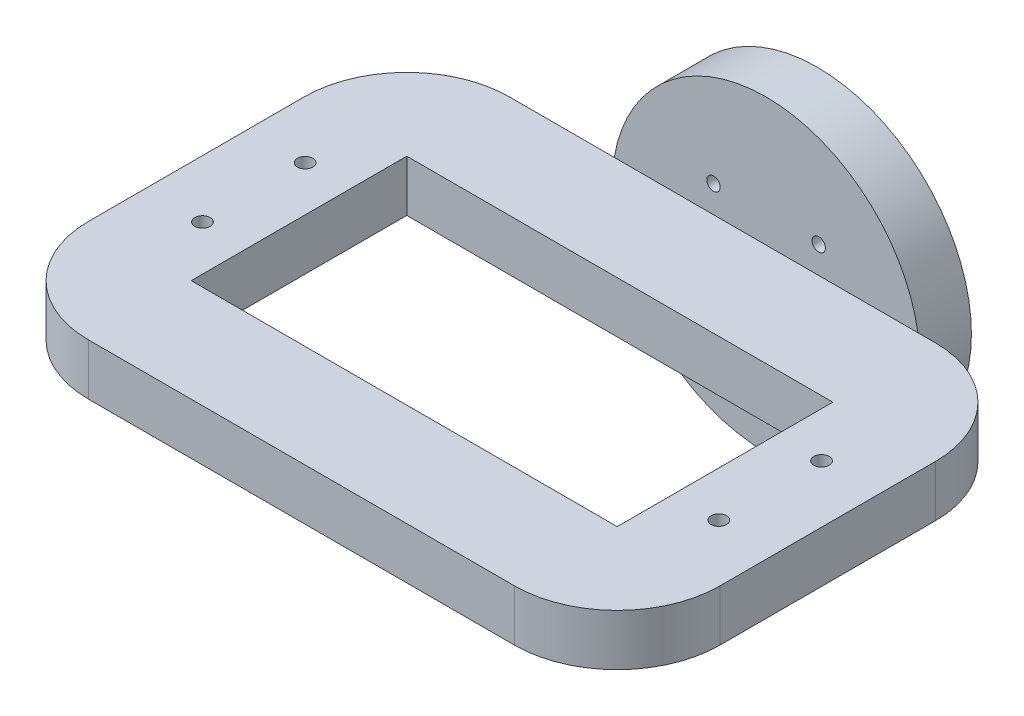
from build123d import *

# Parameters (mm, degrees)
SKETCH1_W           = 61.5
SKETCH1_H           = 30
BOSS_EXTRUDE2_DEPTH = 5
SKETCH2_W           = 61.5
SKETCH2_H           = 5
BOSS_EXTRUDE3_DEPTH = 41
SKETCH3_W           = 41.5
SKETCH3_H           = 21
CUT_EXTRUDE1_DEPTH  = 5
SKETCH4_OUTSIDE_W   = 79.99
SKETCH4_OUTSIDE_H   = 48.49
SKETCH4_OUTSIDE_R   = 15
CUT_EXTRUDE2_DEPTH  = 5
SKETCH5_R           = 3.25
CUT_EXTRUDE5_DEPTH  = 4
FILLET1_R           = 10
FILLET2_R           = 10
FILLET3_R           = 10
FILLET4_R           = 10
SKETCH7_R           = 0.75
CUT_EXTRUDE7_DEPTH  = 5
SKETCH8_R           = 0.65
CUT_EXTRUDE8_DEPTH  = 5


with BuildPart() as part:
    # Sketch1 → Boss-Extrude2 (new body)
    with BuildSketch(Plane.XY):
        with Locations((-30.75, 15)):
            Rectangle(SKETCH1_W, SKETCH1_H)
    extrude(amount=BOSS_EXTRUDE2_DEPTH)

    # Sketch2 → Boss-Extrude3 (add)
    with BuildSketch(Plane.XY.offset(5)):
        with Locations((-30.75, 15)):
            Rectangle(SKETCH2_W, SKETCH2_H)
    extrude(amount=BOSS_EXTRUDE3_DEPTH)

    # Sketch3 → Cut-Extrude1 (cut)
    with BuildSketch(Plane.XZ.offset(-12.5)):
        with Locations((-30.75, 25.5)):
            Rectangle(SKETCH3_W, SKETCH3_H)
    extrude(amount=-CUT_EXTRUDE1_DEPTH, mode=Mode.SUBTRACT)

    # Sketch4 outside → Cut-Extrude2 (cut)
    with BuildSketch(Plane(origin=(0, 0, 0), x_dir=(-1, 0, 0), z_dir=(0, 0, -1))):
        with Locations((30.75, 15)):
            Rectangle(SKETCH4_OUTSIDE_W, SKETCH4_OUTSIDE_H)
        with Locations((26.5, 15)):
            Circle(SKETCH4_OUTSIDE_R, mode=Mode.SUBTRACT)
    extrude(amount=-CUT_EXTRUDE2_DEPTH, mode=Mode.SUBTRACT)

    # Sketch5 → Cut-Extrude5 (cut)
    with BuildSketch(Plane(origin=(0, 0, 0), x_dir=(-1, 0, 0), z_dir=(0, 0, -1))):
        with Locations((26.5, 15)):
            Circle(SKETCH5_R)
    extrude(amount=-CUT_EXTRUDE5_DEPTH, mode=Mode.SUBTRACT)

    # Fillet1
    fillet1_edges = [part.edges().sort_by_distance(p)[0] for p in [
        (-61.5, 15, 5),
    ]]
    fillet(fillet1_edges, radius=FILLET1_R)

    # Fillet2
    fillet2_edges = [part.edges().sort_by_distance(p)[0] for p in [
        (-61.5, 15, 46),
    ]]
    fillet(fillet2_edges, radius=FILLET2_R)

    # Fillet3
    fillet3_edges = [part.edges().sort_by_distance(p)[0] for p in [
        (0, 15, 5),
    ]]
    fillet(fillet3_edges, radius=FILLET3_R)

    # Fillet4
    fillet4_edges = [part.edges().sort_by_distance(p)[0] for p in [
        (0, 15, 46),
    ]]
    fillet(fillet4_edges, radius=FILLET4_R)

    # Sketch7 → Cut-Extrude7 (cut)
    with BuildSketch(Plane.XZ.offset(-12.5)):
        with Locations((-55.9, 20.5)):
            Circle(SKETCH7_R)
        with Locations((-55.9, 30.5)):
            Circle(SKETCH7_R)
        with Locations((-5.6, 30.5)):
            Circle(SKETCH7_R)
        with Locations((-5.6, 20.5)):
            Circle(SKETCH7_R)
    extrude(amount=-CUT_EXTRUDE7_DEPTH, mode=Mode.SUBTRACT)

    # Sketch8 → Cut-Extrude8 (cut)
    with BuildSketch(Plane(origin=(0, 0, 0), x_dir=(-1, 0, 0), z_dir=(0, 0, -1))):
        with Locations((31.626524164, 20.126524164)):
            Circle(SKETCH8_R)
        with Locations((31.626524164, 9.873475836)):
            Circle(SKETCH8_R)
        with Locations((21.373475836, 9.873475836)):
            Circle(SKETCH8_R)
        with Locations((21.373475836, 20.126524164)):
            Circle(SKETCH8_R)
    extrude(amount=-CUT_EXTRUDE8_DEPTH, mode=Mode.SUBTRACT)


solid = part.part
